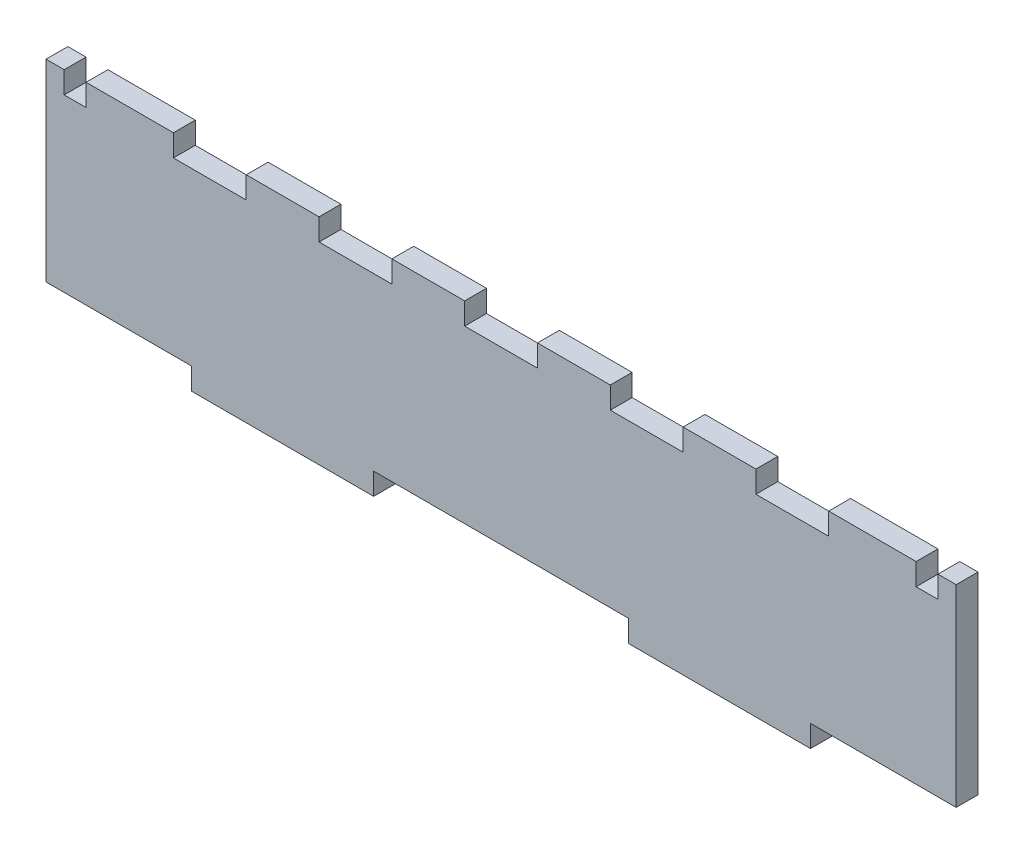
from build123d import *

# Parameters (mm, degrees)
BOSS_EXTRUDE1_DEPTH = 6
CUT_EXTRUDE1_REACH  = 8
SKETCH2_W           = 20
SKETCH2_H           = 6
SKETCH2_W_2         = 6


with BuildPart() as part:
    # Sketch1 → Boss-Extrude1 (new body)
    with BuildSketch(Plane.XY):
        Polygon((-85, -23.5), (-85, -29.5), (-35, -29.5), (-35, -23.5), (35, -23.5), (35, -29.5), (85, -29.5), (85, -23.5), (125, -23.5), (125, 29.5), (-125, 29.5), (-125, -23.5), align=None)
    extrude(amount=BOSS_EXTRUDE1_DEPTH)

    # Sketch2 → Cut-Extrude1 (cut, up to next)
    with BuildSketch(Plane.XY.offset(6), mode=Mode.PRIVATE) as cut_extrude1_sk1:
        with Locations((-80, 26.5)):
            Rectangle(SKETCH2_W, SKETCH2_H)
    cut_extrude1_tool1 = extrude(cut_extrude1_sk1.sketch, amount=-CUT_EXTRUDE1_REACH, mode=Mode.PRIVATE) & part.part
    add(cut_extrude1_tool1.solids().sort_by_distance((-80, 26.5, 6))[0], mode=Mode.SUBTRACT)
    # Sketch2 → Cut-Extrude1 (cut, up to next)
    with BuildSketch(Plane.XY.offset(6), mode=Mode.PRIVATE) as cut_extrude1_sk2:
        with Locations((-40, 26.5)):
            Rectangle(SKETCH2_W, SKETCH2_H)
    cut_extrude1_tool2 = extrude(cut_extrude1_sk2.sketch, amount=-CUT_EXTRUDE1_REACH, mode=Mode.PRIVATE) & part.part
    add(cut_extrude1_tool2.solids().sort_by_distance((-40, 26.5, 6))[0], mode=Mode.SUBTRACT)
    # Sketch2 → Cut-Extrude1 (cut, up to next)
    with BuildSketch(Plane.XY.offset(6), mode=Mode.PRIVATE) as cut_extrude1_sk3:
        with Locations((0, 26.5)):
            Rectangle(SKETCH2_W, SKETCH2_H)
    cut_extrude1_tool3 = extrude(cut_extrude1_sk3.sketch, amount=-CUT_EXTRUDE1_REACH, mode=Mode.PRIVATE) & part.part
    add(cut_extrude1_tool3.solids().sort_by_distance((0, 26.5, 6))[0], mode=Mode.SUBTRACT)
    # Sketch2 → Cut-Extrude1 (cut, up to next)
    with BuildSketch(Plane.XY.offset(6), mode=Mode.PRIVATE) as cut_extrude1_sk4:
        with Locations((40, 26.5)):
            Rectangle(SKETCH2_W, SKETCH2_H)
    cut_extrude1_tool4 = extrude(cut_extrude1_sk4.sketch, amount=-CUT_EXTRUDE1_REACH, mode=Mode.PRIVATE) & part.part
    add(cut_extrude1_tool4.solids().sort_by_distance((40, 26.5, 6))[0], mode=Mode.SUBTRACT)
    # Sketch2 → Cut-Extrude1 (cut, up to next)
    with BuildSketch(Plane.XY.offset(6), mode=Mode.PRIVATE) as cut_extrude1_sk5:
        with Locations((80, 26.5)):
            Rectangle(SKETCH2_W, SKETCH2_H)
    cut_extrude1_tool5 = extrude(cut_extrude1_sk5.sketch, amount=-CUT_EXTRUDE1_REACH, mode=Mode.PRIVATE) & part.part
    add(cut_extrude1_tool5.solids().sort_by_distance((80, 26.5, 6))[0], mode=Mode.SUBTRACT)
    # Sketch2 → Cut-Extrude1 (cut, up to next)
    with BuildSketch(Plane.XY.offset(6), mode=Mode.PRIVATE) as cut_extrude1_sk6:
        with Locations((-117, 26.5)):
            Rectangle(SKETCH2_W_2, SKETCH2_H)
    cut_extrude1_tool6 = extrude(cut_extrude1_sk6.sketch, amount=-CUT_EXTRUDE1_REACH, mode=Mode.PRIVATE) & part.part
    add(cut_extrude1_tool6.solids().sort_by_distance((-117, 26.5, 6))[0], mode=Mode.SUBTRACT)
    # Sketch2 → Cut-Extrude1 (cut, up to next)
    with BuildSketch(Plane.XY.offset(6), mode=Mode.PRIVATE) as cut_extrude1_sk7:
        with Locations((117, 26.5)):
            Rectangle(SKETCH2_W_2, SKETCH2_H)
    cut_extrude1_tool7 = extrude(cut_extrude1_sk7.sketch, amount=-CUT_EXTRUDE1_REACH, mode=Mode.PRIVATE) & part.part
    add(cut_extrude1_tool7.solids().sort_by_distance((117, 26.5, 6))[0], mode=Mode.SUBTRACT)


solid = part.part
